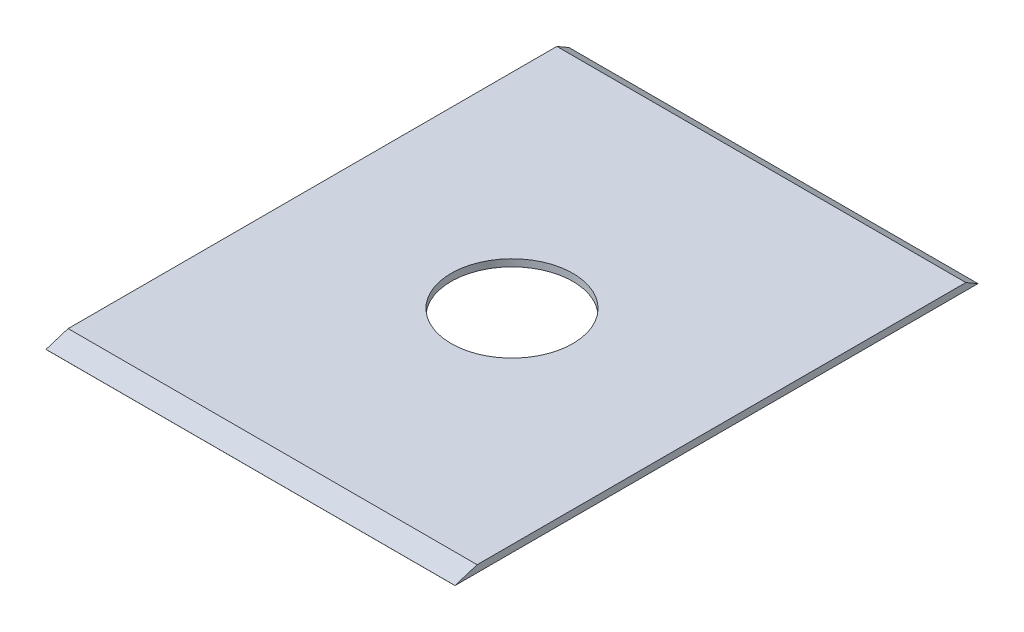
from build123d import *

# Parameters (mm, degrees)
ESQUISSE1_W             = 174.68
ESQUISSE1_H             = 223.37
ESQUISSE1_R             = 26
BOSS_EXTRU_1_DEPTH      = 3
ENL_V_MAT_EXTRU_1_DEPTH = 190


with BuildPart() as part:
    # Esquisse1 → Boss.-Extru.1 (new body)
    with BuildSketch(Plane(origin=(0, 0, 0), x_dir=(1, 0, 0), z_dir=(0, 1, 0))):
        Rectangle(ESQUISSE1_W, ESQUISSE1_H)
        Circle(ESQUISSE1_R, mode=Mode.SUBTRACT)
    extrude(amount=BOSS_EXTRU_1_DEPTH)

    # Esquisse2 → Enlèv. mat.-Extru.1 (cut)
    with BuildSketch(Plane.ZY.offset(87.34)):
        Polygon((-111.685, 0), (-106.491722689, 3), (-111.685, 3), align=None)
        Polygon((102.233000386, 3), (111.685, 0.028240342), (111.685, 3), align=None)
    extrude(amount=-ENL_V_MAT_EXTRU_1_DEPTH, mode=Mode.SUBTRACT)


solid = part.part
